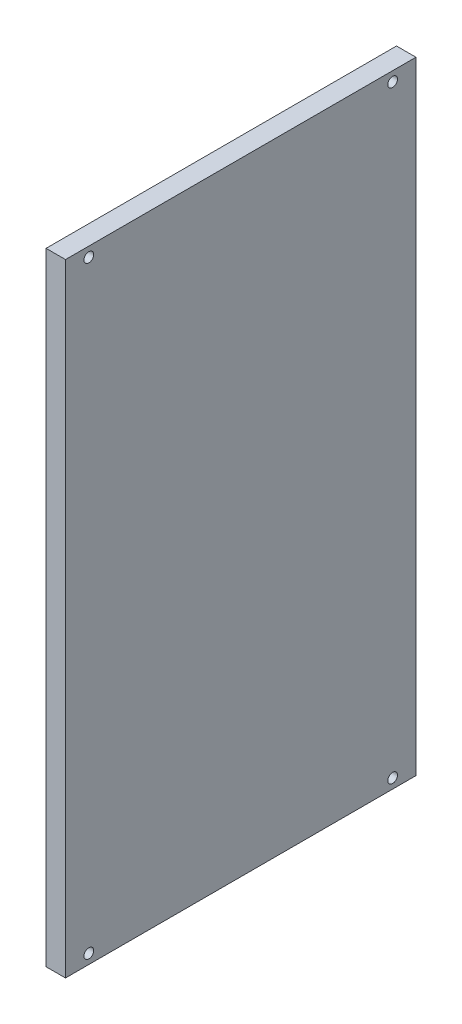
from build123d import *

# Parameters (mm, degrees)
SKETCH1_W           = 180.3
SKETCH1_H           = 320.13
SKETCH1_R           = 2.5
BOSS_EXTRUDE1_DEPTH = 10


with BuildPart() as part:
    # Sketch1 → Boss-Extrude1 (new body)
    with BuildSketch(Plane(origin=(0, 0, 0), x_dir=(0, 0, -1), z_dir=(1, 0, 0))):
        Rectangle(SKETCH1_W, SKETCH1_H)
        with Locations((-78.15, 155.065)):
            Circle(SKETCH1_R, mode=Mode.SUBTRACT)
        with Locations((78.15, 155.065)):
            Circle(SKETCH1_R, mode=Mode.SUBTRACT)
        with Locations((-78.15, -155.065)):
            Circle(SKETCH1_R, mode=Mode.SUBTRACT)
        with Locations((78.15, -155.065)):
            Circle(SKETCH1_R, mode=Mode.SUBTRACT)
    extrude(amount=BOSS_EXTRUDE1_DEPTH)


solid = part.part
